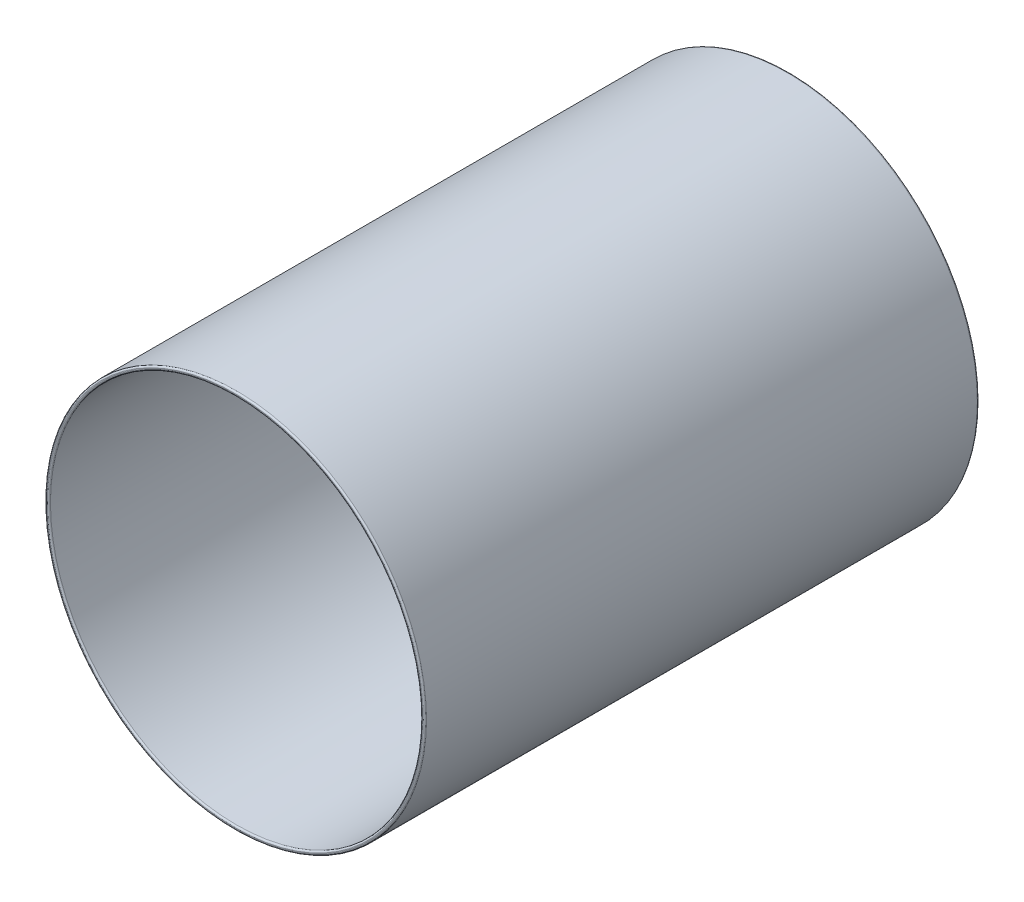
from build123d import *

# Parameters (mm, degrees)
SKETCH1_R           = 240
SKETCH1_R_2         = 235
BOSS_EXTRUDE1_DEPTH = 700
FILLET1_R           = 2


with BuildPart() as part:
    # Sketch1 → Boss-Extrude1 (new body)
    with BuildSketch(Plane.XY):
        Circle(SKETCH1_R)
        Circle(SKETCH1_R_2, mode=Mode.SUBTRACT)
    extrude(amount=-BOSS_EXTRUDE1_DEPTH)

    # Fillet1
    fillet1_edges = [part.edges().sort_by_distance(p)[0] for p in [
        (-240, 0, 0),
        (-240, 0, -700),
        (-235, 0, -700),
        (-235, 0, 0),
    ]]
    fillet(fillet1_edges, radius=FILLET1_R)


solid = part.part
